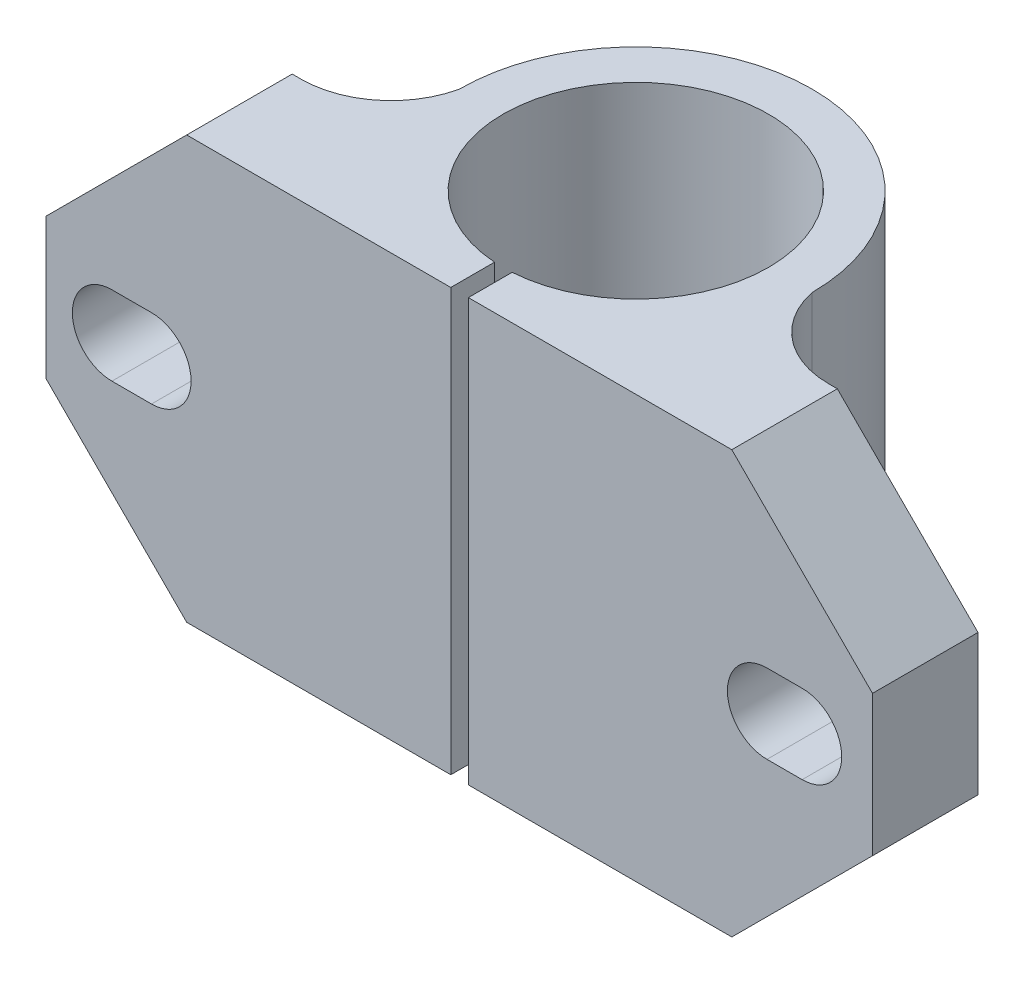
from build123d import *

# Parameters (mm, degrees)
BOSS_EXTRUDE1_DEPTH            = 24
CUT_EXTRUDE1_DEPTH             = 25
SKETCH3_W                      = 7.55
SKETCH3_H                      = 24
F_4_5_4_5_DIAMETER_HOLE1_D     = 4.5
F_4_5_4_5_DIAMETER_HOLE1_DEPTH = 6
CHAMFER1_SIZE                  = 8
CUT_EXTRUDE2_DEPTH             = 21.045442769


with BuildPart() as part:
    # Sketch1 → Boss-Extrude1 (new body)
    with BuildSketch(Plane(origin=(0, 24, 0), x_dir=(1, 0, 0), z_dir=(0, 1, 0))):
        with BuildLine():
            Line((0, 0), (47, 0))
            Line((47, 0), (47, 6))
            Line((47, 6), (38.5, 6))
            ThreePointArc((38.5, 6), (35.307693119, 7.131854655), (33.541354656, 10.021831577))
            ThreePointArc((33.541354656, 10.021831577), (23.505747016, 20.045434485), (13.49594739, 9.996059012))
            ThreePointArc((13.49594739, 9.996059012), (11.698748894, 7.121907302), (8.5, 6))
            Line((8.5, 6), (0, 6))
            Line((0, 6), (0, 0))
        make_face()
    extrude(amount=-BOSS_EXTRUDE1_DEPTH)

    # Sketch2 → Cut-Extrude1 (cut, through all)
    with BuildSketch(Plane.XZ):
        with BuildLine():
            Line((24.018633311, 0), (23.018633311, 0))
            Line((23.018633311, 0), (23.018633311, -2.489295869))
            ThreePointArc((23.018633311, -2.489295869), (23.518633311, -2.472721384), (24.018633311, -2.489295869))
            Line((24.018633311, -2.489295869), (24.018633311, 0))
        make_face()
    extrude(amount=-CUT_EXTRUDE1_DEPTH, mode=Mode.SUBTRACT)

    # Sketch3 → Cut-Revolve1 (revolve, cut)
    with BuildSketch(Plane(origin=(0, 0, -10.022721384), x_dir=(-1, 0, 0), z_dir=(0, 0, -1))):
        with Locations((-27.293633311, 12)):
            Rectangle(SKETCH3_W, SKETCH3_H)
    revolve(axis=Axis((23.518633311, 0, -10.022721384), (0, 1, 0)), mode=Mode.SUBTRACT)

    # Ø4.5 (4.5) Diameter Hole1
    with Locations(Plane(origin=(0, 0, -6), x_dir=(-1, 0, 0), z_dir=(0, 0, -1))):
        with Locations((-41.037266621, 12), (-6, 12)):
            Hole(F_4_5_4_5_DIAMETER_HOLE1_D / 2, depth=F_4_5_4_5_DIAMETER_HOLE1_DEPTH)

    # Chamfer1
    chamfer1_edges = [part.edges().sort_by_distance(p)[0] for p in [
        (47, 0, -3),
        (0, 24, -3),
        (0, 0, -3),
        (47, 24, -3),
    ]]
    chamfer(chamfer1_edges, length=CHAMFER1_SIZE)

    # Sketch7 → Cut-Extrude2 (cut, through all)
    with BuildSketch(Plane.XY):
        with BuildLine():
            Line((41, 14.25), (43, 14.25))
            ThreePointArc((43, 14.25), (45.25, 12), (43, 9.75))
            Line((43, 9.75), (41, 9.75))
            ThreePointArc((41, 9.75), (38.75, 12), (41, 14.25))
        make_face()
        with BuildLine():
            Line((6, 9.75), (3.75, 9.75))
            ThreePointArc((3.75, 9.75), (1.5, 12), (3.75, 14.25))
            Line((3.75, 14.25), (6, 14.25))
            ThreePointArc((6, 14.25), (8.25, 12), (6, 9.75))
        make_face()
    extrude(amount=-CUT_EXTRUDE2_DEPTH, mode=Mode.SUBTRACT)


solid = part.part
